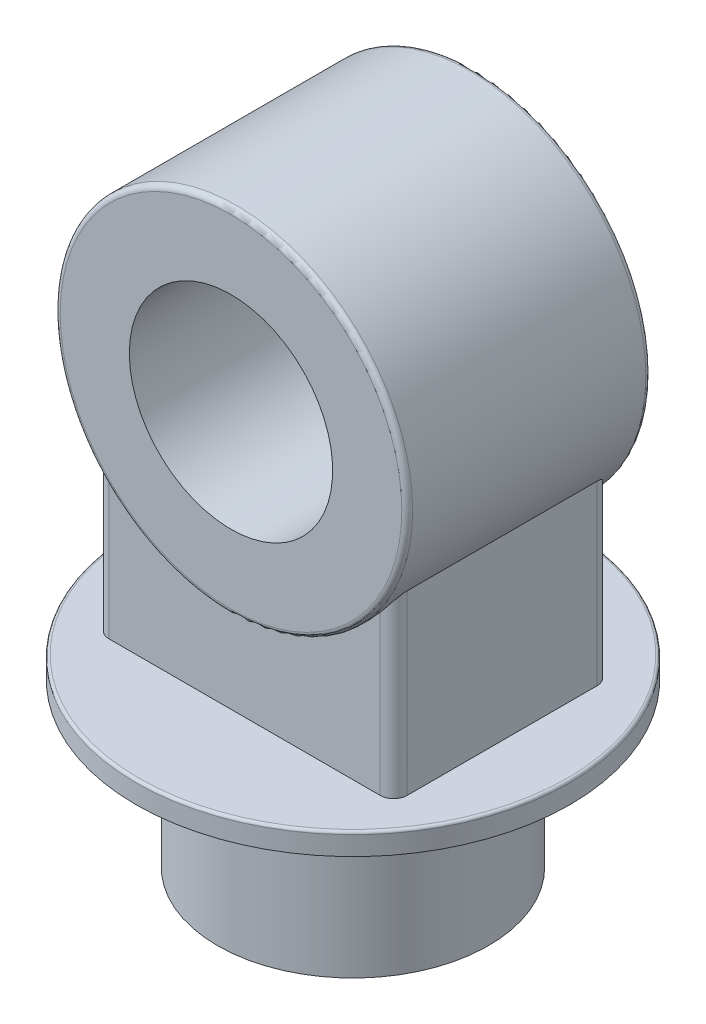
from build123d import *

# Parameters (mm, degrees)
SKETCH1_R                = 100
BOSS_EXTRUDE1_DEPTH      = 120
SKETCH2_R                = 160
BOSS_EXTRUDE2_DEPTH      = 16
SKETCH3_R                = 130
SKETCH3_R_2              = 75
BOSS_EXTRUDE3_DEPTH      = 90
BOSS_EXTRUDE4_REACH      = 402.125
BOSS_EXTRUDE4_END_RADIUS = 130
SKETCH4_W                = 220
SKETCH4_H                = 160
FILLET1_R                = 2
FILLET2_R                = 4
FILLET3_R                = 10


with BuildPart() as part:
    # Sketch1 → Boss-Extrude1 (new body)
    with BuildSketch(Plane(origin=(0, 0, 0), x_dir=(1, 0, 0), z_dir=(0, 1, 0))):
        with Locations(Location((0, 0, 0), (0, 0, 270))):
            Circle(SKETCH1_R)
    extrude(amount=BOSS_EXTRUDE1_DEPTH)

    # Sketch2 → Boss-Extrude2 (add)
    with BuildSketch(Plane(origin=(0, 120, 0), x_dir=(1, 0, 0), z_dir=(0, 1, 0))):
        with Locations(Location((0, 0, 0), (0, 0, 270))):
            Circle(SKETCH2_R)
    extrude(amount=BOSS_EXTRUDE2_DEPTH)



with BuildPart() as body_2:
    # Sketch3 → Boss-Extrude3 (new, symmetric)
    with BuildSketch(Plane.XY):
        with Locations(Location((0, 336, 0), (0, 0, 180))):
            Circle(SKETCH3_R)
        with Locations(Location((0, 336, 0), (0, 0, 180))):
            Circle(SKETCH3_R_2, mode=Mode.SUBTRACT)
    extrude(amount=BOSS_EXTRUDE3_DEPTH, both=True)


with BuildPart() as part_1:
    add(part.part)

    add(body_2.part)  # Boss-Extrude4 merges body 2
    # Boss-Extrude4: up to this cylinder (the profile starts outside it)
    boss_extrude4_end = Plane(origin=(0, 336, 0), z_dir=(0, 0, -1)) * Cylinder(BOSS_EXTRUDE4_END_RADIUS, 1065.25, mode=Mode.PRIVATE)
    # Sketch4 → Boss-Extrude4 (add, up to the surface)
    with BuildSketch(Plane(origin=(0, 136, 0), x_dir=(1, 0, 0), z_dir=(0, 1, 0)), mode=Mode.PRIVATE) as boss_extrude4_sk1:
        Rectangle(SKETCH4_W, SKETCH4_H)
    boss_extrude4_tool1 = extrude(boss_extrude4_sk1.sketch, amount=BOSS_EXTRUDE4_REACH, mode=Mode.PRIVATE) - boss_extrude4_end
    add(boss_extrude4_tool1.solids().sort_by_distance((0, 136, 0))[0])

    # Fillet1
    fillet1_edges = [part_1.edges().sort_by_distance(p)[0] for p in [
        (0, 136, -160),
    ]]
    fillet(fillet1_edges, radius=FILLET1_R)

    # Fillet2
    fillet2_edges = [part_1.edges().sort_by_distance(p)[0] for p in [
        (130, 336, -90),
        (130, 336, 90),
    ]]
    fillet(fillet2_edges, radius=FILLET2_R)

    # Fillet3
    fillet3_edges = [part_1.edges().sort_by_distance(p)[0] for p in [
        (-110, 201.358983849, 80),
        (-110, 201.358983849, -80),
        (110, 201.358983849, 80),
        (110, 201.358983849, -80),
    ]]
    fillet(fillet3_edges, radius=FILLET3_R)


solid = part_1.part
